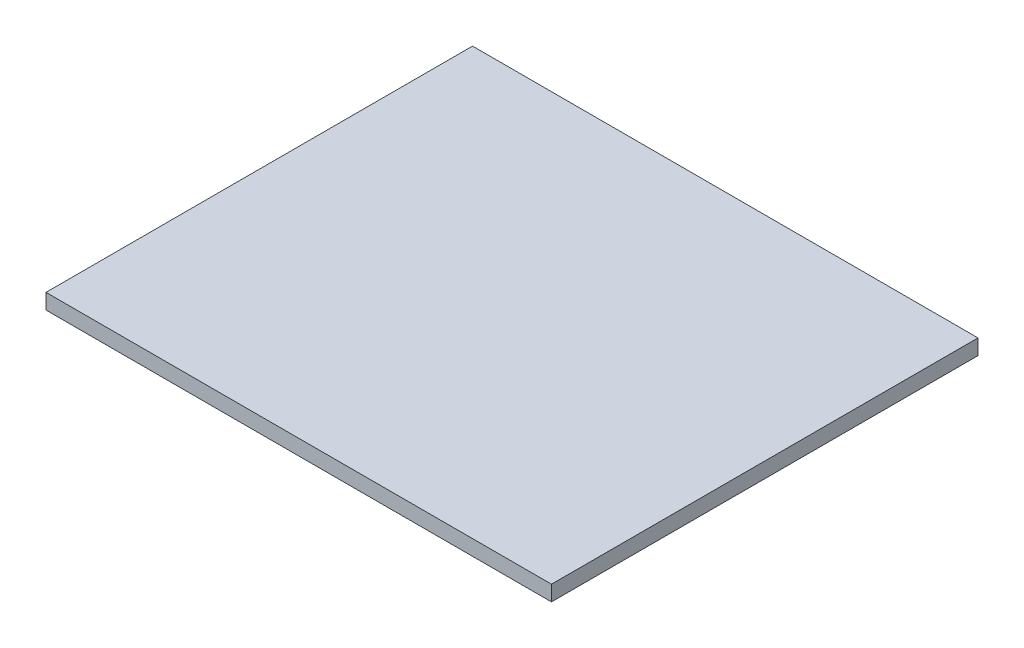
from build123d import *

# Parameters (mm, degrees)
SKETCH1_W           = 88.88
SKETCH1_H           = 75
BOSS_EXTRUDE1_DEPTH = 2.7


with BuildPart() as part:
    # Sketch1 → Boss-Extrude1 (new body)
    with BuildSketch(Plane(origin=(0, 0, 0), x_dir=(1, 0, 0), z_dir=(0, 1, 0))):
        Rectangle(SKETCH1_W, SKETCH1_H)
    extrude(amount=BOSS_EXTRUDE1_DEPTH)


solid = part.part
